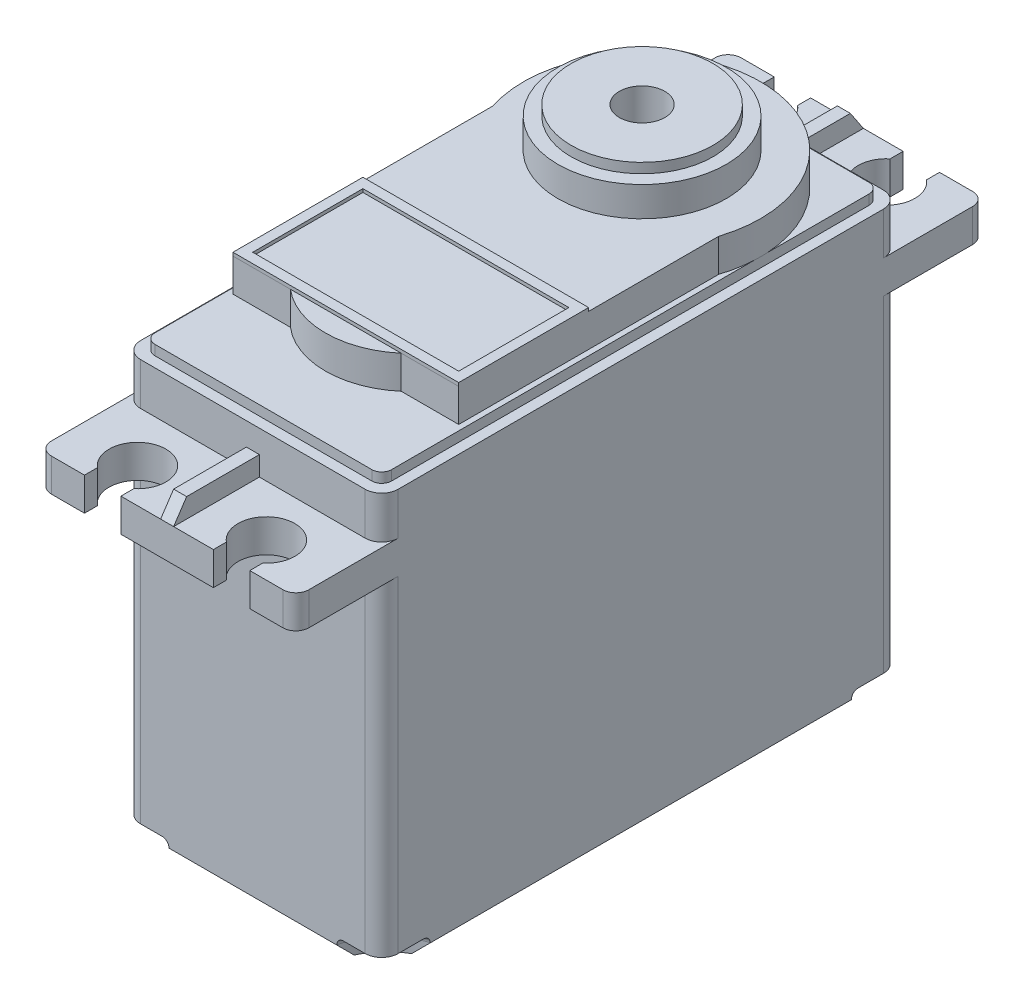
from build123d import *

# Parameters (mm, degrees)
SKETCH1_W               = 19.82
SKETCH1_H               = 39.88
BOSS_EXTRUDE1_DEPTH     = 36.02
SKETCH2_W               = 19.82
SKETCH2_H               = 6.6
BOSS_EXTRUDE2_DEPTH     = 2.54
CUT_EXTRUDE1_DEPTH      = 2.54
SKETCH4_W               = 1
SKETCH4_H               = 6.6
BOSS_EXTRUDE3_DEPTH     = 1.5
CUT_EXTRUDE2_DEPTH      = 10.41
CUT_EXTRUDE2_DEPTH_BACK = 11.41
SKETCH6_W               = 19.82
SKETCH6_H               = 39.88
CUT_EXTRUDE3_DEPTH      = 3.55
SKETCH7_W               = 18.22
SKETCH7_H               = 38.272033082
BOSS_EXTRUDE4_DEPTH     = 0.762
FILLET1_R               = 1.27
FILLET2_R               = 0.762
BOSS_EXTRUDE5_DEPTH     = 2.54
SKETCH9_R               = 6.475
BOSS_EXTRUDE6_DEPTH     = 2.286
SKETCH10_R              = 5.46
BOSS_EXTRUDE7_DEPTH     = 0.762
SKETCH11_R              = 1.75
CUT_EXTRUDE4_DEPTH      = 2.54
SKETCH12_W              = 17.371497452
SKETCH12_H              = 10
SKETCH12_W_2            = 15.851497452
SKETCH12_H_2            = 8.48
BOSS_EXTRUDE8_DEPTH     = 0.254
BOSS_EXTRUDE9_DEPTH     = 2.54
CUT_EXTRUDE5_DEPTH      = 1.524
SKETCH15_R              = 0.5
CUT_EXTRUDE6_DEPTH      = 6
CHAMFER1_SIZE           = 1
FILLET3_R               = 0.5
SKETCH16_W              = 6.35
SKETCH16_H              = 3.686799723
SKETCH16_W_2            = 5.35
SKETCH16_H_2            = 2.686799723
BOSS_EXTRUDE10_DEPTH    = 1.5
FILLET4_R               = 0.5
FILLET5_R               = 1


with BuildPart() as part:
    # Sketch1 → Boss-Extrude1 (new body)
    with BuildSketch(Plane(origin=(0, 0, 0), x_dir=(1, 0, 0), z_dir=(0, 1, 0))):
        Rectangle(SKETCH1_W, SKETCH1_H)
    extrude(amount=BOSS_EXTRUDE1_DEPTH)

    # Sketch2 → Boss-Extrude2 (add)
    with BuildSketch(Plane(origin=(0, 26.67, 0), x_dir=(1, 0, 0), z_dir=(0, 1, 0))):
        with Locations((0, 23.24)):
            Rectangle(SKETCH2_W, SKETCH2_H)
        with Locations((0, -23.24)):
            Rectangle(SKETCH2_W, SKETCH2_H)
    extrude(amount=BOSS_EXTRUDE2_DEPTH)

    # Sketch3 → Cut-Extrude1 (cut)
    with BuildSketch(Plane(origin=(0, 29.21, 0), x_dir=(1, 0, 0), z_dir=(0, 1, 0))):
        with BuildLine():
            Line((-3.56, 26.54), (-6.36, 26.54))
            Line((-6.36, 26.54), (-6.36, 25.544072445))
            ThreePointArc((-6.36, 25.544072445), (-4.96, 21.67), (-3.56, 25.544072445))
            Line((-3.56, 25.544072445), (-3.56, 26.54))
        make_face()
        with BuildLine():
            Line((6.36, 26.54), (3.56, 26.54))
            Line((3.56, 26.54), (3.56, 25.544072445))
            ThreePointArc((3.56, 25.544072445), (4.96, 21.67), (6.36, 25.544072445))
            Line((6.36, 25.544072445), (6.36, 26.54))
        make_face()
    cut_extrude1 = extrude(amount=-CUT_EXTRUDE1_DEPTH, mode=Mode.SUBTRACT)

    # Mirror1: Cut-Extrude1 across plane
    add(cut_extrude1.mirror(Plane.XY), mode=Mode.SUBTRACT)

    # Sketch4 → Boss-Extrude3 (add)
    with BuildSketch(Plane(origin=(0, 29.21, 0), x_dir=(1, 0, 0), z_dir=(0, 1, 0))):
        with Locations((0, 23.24)):
            Rectangle(SKETCH4_W, SKETCH4_H)
        with Locations((0, -23.24)):
            Rectangle(SKETCH4_W, SKETCH4_H)
    extrude(amount=BOSS_EXTRUDE3_DEPTH)

    # Sketch5 → Cut-Extrude2 (cut, two sides)
    with BuildSketch(Plane.ZY.offset(0.5)) as cut_extrude2_sk:
        Polygon((-26.54, 30.71), (-25.54, 30.71), (-26.54, 29.21), align=None)
        Polygon((25.54, 30.71), (26.54, 29.21), (26.54, 30.71), align=None)
    extrude(amount=CUT_EXTRUDE2_DEPTH, mode=Mode.SUBTRACT)
    extrude(cut_extrude2_sk.sketch, amount=-CUT_EXTRUDE2_DEPTH_BACK, mode=Mode.SUBTRACT)

    # Sketch6 → Cut-Extrude3 (cut)
    with BuildSketch(Plane(origin=(0, 36.02, 0), x_dir=(1, 0, 0), z_dir=(0, 1, 0))):
        Rectangle(SKETCH6_W, SKETCH6_H)
    extrude(amount=-CUT_EXTRUDE3_DEPTH, mode=Mode.SUBTRACT)

    # Sketch7 → Boss-Extrude4 (add)
    with BuildSketch(Plane(origin=(0, 32.47, 0), x_dir=(1, 0, 0), z_dir=(0, 1, 0))):
        Rectangle(SKETCH7_W, SKETCH7_H)
    extrude(amount=BOSS_EXTRUDE4_DEPTH)

    # Fillet1
    fillet1_edges = [part.edges().sort_by_distance(p)[0] for p in [
        (-9.91, 13.335, -19.94),
        (9.91, 13.335, -19.94),
        (9.91, 30.84, -19.94),
        (9.91, 30.84, 19.94),
        (-9.91, 30.84, 19.94),
        (-9.91, 30.84, -19.94),
        (9.91, 13.335, 19.94),
        (-9.91, 13.335, 19.94),
    ]]
    fillet(fillet1_edges, radius=FILLET1_R)

    # Fillet2
    fillet2_edges = [part.edges().sort_by_distance(p)[0] for p in [
        (9.11, 32.851, -19.136016541),
        (-9.11, 32.851, -19.136016541),
        (-9.11, 32.851, 19.136016541),
        (9.11, 32.851, 19.136016541),
    ]]
    fillet(fillet2_edges, radius=FILLET2_R)

    # Sketch8 → Boss-Extrude5 (add)
    with BuildSketch(Plane(origin=(0, 33.232, 0), x_dir=(1, 0, 0), z_dir=(0, 1, 0))):
        with BuildLine():
            Line((-8.685748726, -12.786016541), (8.685748726, -12.786016541))
            Line((8.685748726, -12.786016541), (8.685748726, 7.213983459))
            ThreePointArc((8.685748726, 7.213983459), (0, 19.136016541), (-8.685748726, 7.213983459))
            Line((-8.685748726, 7.213983459), (-8.685748726, -12.786016541))
        make_face()
    extrude(amount=BOSS_EXTRUDE5_DEPTH)

    # Sketch9 → Boss-Extrude6 (add)
    with BuildSketch(Plane(origin=(0, 35.772, 0), x_dir=(1, 0, 0), z_dir=(0, 1, 0))):
        with Locations((0, 10.011016541)):
            Circle(SKETCH9_R)
    extrude(amount=BOSS_EXTRUDE6_DEPTH)

    # Sketch10 → Boss-Extrude7 (add)
    with BuildSketch(Plane(origin=(0, 38.058, 0), x_dir=(1, 0, 0), z_dir=(0, 1, 0))):
        with Locations((0, 10.011016541)):
            Circle(SKETCH10_R)
    extrude(amount=BOSS_EXTRUDE7_DEPTH)

    # Sketch11 → Cut-Extrude4 (cut)
    with BuildSketch(Plane(origin=(0, 38.82, 0), x_dir=(1, 0, 0), z_dir=(0, 1, 0))):
        with Locations((0, 10.011016541)):
            Circle(SKETCH11_R)
    extrude(amount=-CUT_EXTRUDE4_DEPTH, mode=Mode.SUBTRACT)

    # Sketch12 → Boss-Extrude8 (add)
    with BuildSketch(Plane(origin=(0, 35.772, 0), x_dir=(1, 0, 0), z_dir=(0, 1, 0))):
        with Locations((0, -7.788983459)):
            Rectangle(SKETCH12_W, SKETCH12_H)
        with Locations((0, -7.788983459)):
            Rectangle(SKETCH12_W_2, SKETCH12_H_2, mode=Mode.SUBTRACT)
    extrude(amount=BOSS_EXTRUDE8_DEPTH)

    # Sketch13 → Boss-Extrude9 (add)
    with BuildSketch(Plane(origin=(0, 33.232, 0), x_dir=(1, 0, 0), z_dir=(0, 1, 0))):
        with BuildLine():
            Line((-4.260837189, -12.79), (4.260837189, -12.79))
            ThreePointArc((4.260837189, -12.79), (0, -14.358983459), (-4.260837189, -12.79))
        make_face()
    extrude(amount=BOSS_EXTRUDE9_DEPTH)

    # Sketch14 → Cut-Extrude5 (cut)
    with BuildSketch(Plane.XZ):
        with BuildLine():
            Line((6.46365167, -19.94), (9.91, -19.94))
            Line((9.91, -19.94), (9.91, -16.211847956))
            ThreePointArc((9.91, -16.211847956), (7.678426739, -17.605953774), (6.46365167, -19.94))
        make_face()
        with BuildLine():
            Line((-9.91, -19.94), (-9.91, -16.211847956))
            ThreePointArc((-9.91, -16.211847956), (-7.678426739, -17.605953774), (-6.46365167, -19.94))
            Line((-6.46365167, -19.94), (-9.91, -19.94))
        make_face()
        with BuildLine():
            Line((-6.46365167, 19.94), (-9.91, 19.94))
            Line((-9.91, 19.94), (-9.91, 16.211847956))
            ThreePointArc((-9.91, 16.211847956), (-7.678426739, 17.605953774), (-6.46365167, 19.94))
        make_face()
        with BuildLine():
            Line((9.91, 19.94), (9.91, 16.211847956))
            ThreePointArc((9.91, 16.211847956), (7.678426739, 17.605953774), (6.46365167, 19.94))
            Line((6.46365167, 19.94), (9.91, 19.94))
        make_face()
    extrude(amount=-CUT_EXTRUDE5_DEPTH, mode=Mode.SUBTRACT)

    # Sketch15 → Cut-Extrude6 (cut)
    with BuildSketch(Plane(origin=(0, 0, 0), x_dir=(-1, 0, 0), z_dir=(0, -1, 0))):
        with Locations((-8.64, 18.67)):
            Circle(SKETCH15_R)
        with Locations((8.64, 18.67)):
            Circle(SKETCH15_R)
        with Locations((8.64, -18.67)):
            Circle(SKETCH15_R)
        with Locations((-8.64, -18.67)):
            Circle(SKETCH15_R)
    extrude(amount=-CUT_EXTRUDE6_DEPTH, mode=Mode.SUBTRACT)

    # Chamfer1
    chamfer1_edges = [part.edges().sort_by_distance(p)[0] for p in [
        (0, 0, 19.94),
        (-9.91, 0, 0),
        (0, 0, -19.94),
        (9.91, 0, 0),
    ]]
    chamfer(chamfer1_edges, length=CHAMFER1_SIZE)

    # Fillet3
    fillet3_edges = [part.edges().sort_by_distance(p)[0] for p in [
        (7.678426739, 1.524, 17.605953774),
        (-7.678426739, 1.524, 17.605953774),
        (-7.678426739, 1.524, -17.605953774),
        (7.678426739, 1.524, -17.605953774),
    ]]
    fillet(fillet3_edges, radius=FILLET3_R)

    # Sketch16 → Boss-Extrude10 (add)
    with BuildSketch(Plane(origin=(0, 0, -19.94), x_dir=(-1, 0, 0), z_dir=(0, 0, -1))):
        with Locations((0, 2.843399862)):
            Rectangle(SKETCH16_W, SKETCH16_H)
        with Locations((0, 2.843399862)):
            Rectangle(SKETCH16_W_2, SKETCH16_H_2, mode=Mode.SUBTRACT)
    extrude(amount=BOSS_EXTRUDE10_DEPTH)

    # Fillet4
    fillet4_edges = [part.edges().sort_by_distance(p)[0] for p in [
        (3.175, 4.686799723, -20.69),
        (3.175, 1, -20.69),
        (-3.175, 1, -20.69),
        (-3.175, 4.686799723, -20.69),
    ]]
    fillet(fillet4_edges, radius=FILLET4_R)

    # Fillet5
    fillet5_edges = [part.edges().sort_by_distance(p)[0] for p in [
        (-9.91, 27.94, -26.54),
        (9.91, 27.94, -26.54),
        (-9.91, 27.94, 26.54),
        (9.91, 27.94, 26.54),
    ]]
    fillet(fillet5_edges, radius=FILLET5_R)


solid = part.part
